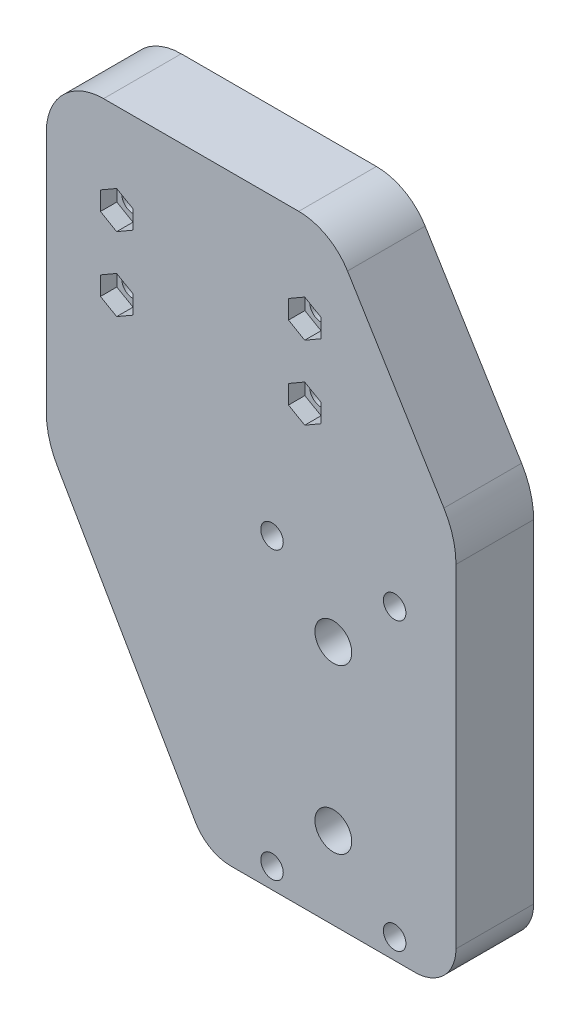
from build123d import *

# Parameters (mm, degrees)
BOSS_EXTRUDE1_DEPTH  = 19
FILLET1_R            = 10
M5_CLEARANCE_HOLE2_D = 5.5
M5_CLEARANCE_HOLE1_D = 5.5
FILLET2_R            = 4
BOSS_EXTRUDE2_DEPTH  = 19
M8_CLEARANCE_HOLE1_D = 9
CUT_EXTRUDE2_DEPTH   = 4
SKETCH16_R           = 10
CUT_EXTRUDE3_DEPTH   = 5


with BuildPart() as part:
    # Sketch1 → Boss-Extrude1 (new body)
    with BuildSketch(Plane.XY):
        with BuildLine():
            Line((-170.200000001, 540.824594888), (-129.309401077, 470))
            Line((-129.309401077, 470), (-93, 470))
            ThreePointArc((-93, 470), (-90.878679656, 470.878679656), (-90, 473))
            Line((-90, 473), (-90, 564.25527297))
            Line((-90, 564.25527297), (-116.225329238, 607))
            Line((-116.225329238, 607), (-170.200000001, 607))
            Line((-170.200000001, 607), (-170.200000001, 540.824594888))
        make_face()
    extrude(amount=BOSS_EXTRUDE1_DEPTH)

    # Fillet1
    fillet1_edges = [part.edges().sort_by_distance(p)[0] for p in [
        (-90, 564.25527297, 9.5),
        (-129.309401077, 470, 9.5),
        (-170.200000001, 540.824594888, 9.5),
    ]]
    fillet(fillet1_edges, radius=FILLET1_R)

    # M5 Clearance Hole2 (through all)
    with Locations(Plane(origin=(0, 0, 0), x_dir=(-1, 0, 0), z_dir=(0, 0, -1))):
        with Locations((117.000000001, 595), (117.000000001, 577), (163.000000001, 577), (163.000000001, 595)):
            Hole(M5_CLEARANCE_HOLE2_D / 2)

    # M5 Clearance Hole1 (through all)
    with Locations(Plane.XY.offset(19)):
        with Locations((-95, 545), (-125, 545), (-125, 475), (-95, 475), (-110, 490), (-110, 530)):
            Hole(M5_CLEARANCE_HOLE1_D / 2)

    # Fillet2
    fillet2_edges = [part.edges().sort_by_distance(p)[0] for p in [
        (-116.225329238, 607, 9.5),
        (-170.200000001, 607, 9.5),
    ]]
    fillet(fillet2_edges, radius=FILLET2_R)

    # Sketch11 → Boss-Extrude2 (add)
    with BuildSketch(Plane.XY.offset(19)):
        with BuildLine():
            ThreePointArc((-143.743157806, 475), (-140.082903769, 471.339745962), (-135.082903769, 470))
            Line((-135.082903769, 470), (-123.535898385, 470))
            ThreePointArc((-123.535898385, 470), (-128.535898385, 471.339745962), (-132.196152423, 475))
            Line((-132.196152423, 475), (-168.860254039, 538.504086813))
            ThreePointArc((-168.860254039, 538.504086813), (-169.859258264, 540.915896362), (-170.200000001, 543.504086813))
            Line((-170.200000001, 543.504086813), (-170.200000001, 603))
            ThreePointArc((-170.200000001, 603), (-169.028427125, 605.828427125), (-166.200000001, 607))
            Line((-166.200000001, 607), (-118.464037729, 607))
            ThreePointArc((-118.464037729, 607), (-116.510482263, 606.490504411), (-115.054590744, 605.091810521))
            Line((-115.054590744, 605.091810521), (-91.476382537, 566.661632408))
            ThreePointArc((-91.476382537, 566.661632408), (-90.37617086, 564.149073659), (-90, 561.432106106))
            Line((-90, 561.432106106), (-90, 473))
            ThreePointArc((-90, 473), (-90.878679656, 470.878679656), (-93, 470))
            Line((-93, 470), (-90, 470))
            ThreePointArc((-90, 470), (-82.928932188, 472.928932188), (-80, 480))
            Line((-80, 480), (-80, 561.432106106))
            ThreePointArc((-80, 561.432106106), (-80.75234172, 566.866041212), (-82.952765074, 571.89115871))
            Line((-82.952765074, 571.89115871), (-106.530973281, 610.321336823))
            ThreePointArc((-106.530973281, 610.321336823), (-111.626593598, 615.216765438), (-118.464037729, 617))
            Line((-118.464037729, 617), (-166.200000001, 617))
            ThreePointArc((-166.200000001, 617), (-176.099494937, 612.899494937), (-180.200000001, 603))
            Line((-180.200000001, 603), (-180.200000001, 543.504086813))
            ThreePointArc((-180.200000001, 543.504086813), (-179.518516526, 538.327705911), (-177.520508076, 533.504086813))
            Line((-177.520508076, 533.504086813), (-143.743157806, 475))
        make_face()
    extrude(amount=-BOSS_EXTRUDE2_DEPTH)

    # M8 Clearance Hole1 (through all)
    with Locations(Plane.XY.offset(19)):
        with Locations((-110, 530), (-110, 490)):
            Hole(M8_CLEARANCE_HOLE1_D / 2)

    # Sketch15 → Cut-Extrude2 (cut)
    with BuildSketch(Plane.XY.offset(19)):
        Polygon((-166.960000001, 579.286307066), (-166.960000001, 574.713692934), (-163.000000001, 572.427385868), (-159.040000001, 574.713692934), (-159.040000001, 579.286307066), (-163.000000001, 581.572614132), align=None)
        Polygon((-120.960000001, 579.286307066), (-120.960000001, 574.713692934), (-117.000000001, 572.427385868), (-113.040000001, 574.713692934), (-113.040000001, 579.286307066), (-117.000000001, 581.572614132), align=None)
        Polygon((-113.040000001, 592.713692934), (-117.000000001, 590.427385868), (-120.960000001, 592.713692934), (-120.960000001, 597.286307066), (-117.000000001, 599.572614132), (-113.040000001, 597.286307066), align=None)
        Polygon((-163.000000001, 590.427385868), (-166.960000001, 592.713692934), (-166.960000001, 597.286307066), (-163.000000001, 599.572614132), (-159.040000001, 597.286307066), (-159.040000001, 592.713692934), align=None)
    extrude(amount=-CUT_EXTRUDE2_DEPTH, mode=Mode.SUBTRACT)

    # Sketch16 → Cut-Extrude3 (cut)
    with BuildSketch(Plane(origin=(0, 0, 0), x_dir=(-1, 0, 0), z_dir=(0, 0, -1))):
        with Locations((140.000000001, 577)):
            Circle(SKETCH16_R)
    extrude(amount=-CUT_EXTRUDE3_DEPTH, mode=Mode.SUBTRACT)


solid = part.part
